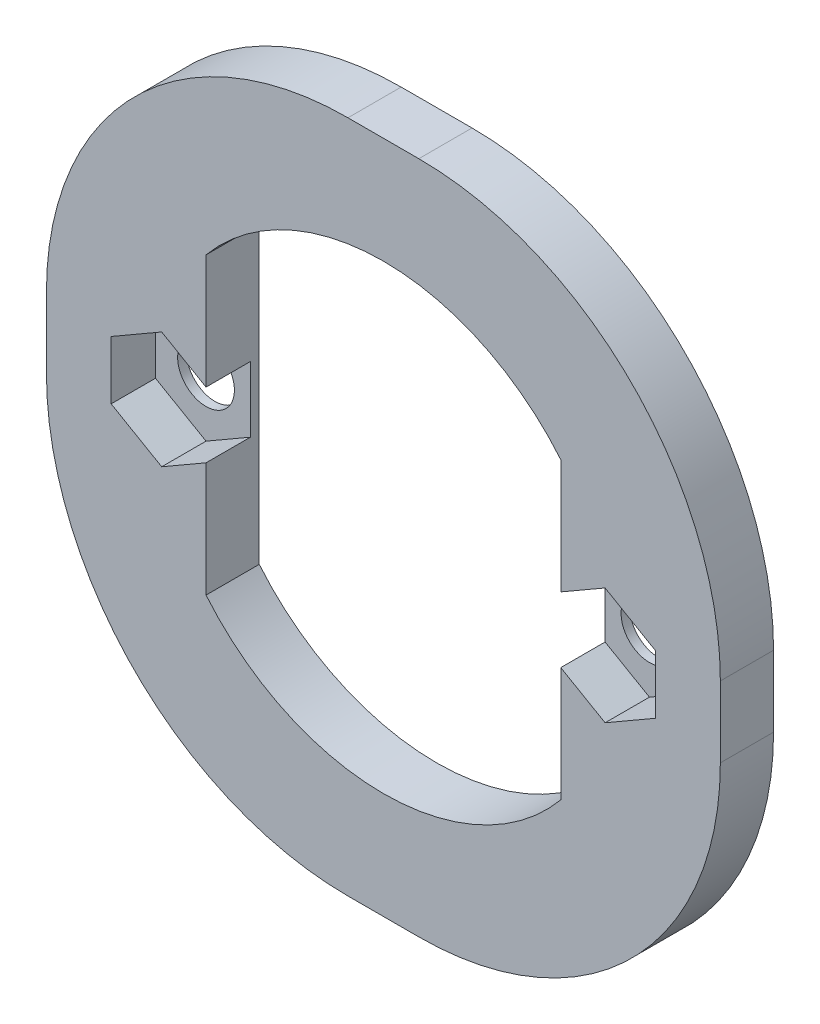
from build123d import *

# Parameters (mm, degrees)
BOSS_EXTRUDE5_DEPTH = 3
SKETCH2_R           = 1.6
CUT_EXTRUDE2_DEPTH  = 4
CUT_EXTRUDE3_DEPTH  = 2.5


with BuildPart() as part:
    # Sketch1 → Boss-Extrude5 (new body)
    with BuildSketch(Plane.XY):
        with BuildLine():
            Line((-1.997893001, -19), (1.997893001, -19))
            ThreePointArc((1.997893001, -19), (14.018708281, -14.02081528), (18.997893001, -2))
            Line((18.997893001, -2), (18.997893001, 2))
            ThreePointArc((18.997893001, 2), (14.018708281, 14.02081528), (1.997893001, 19))
            Line((1.997893001, 19), (-1.997893001, 19))
            ThreePointArc((-1.997893001, 19), (-14.018708281, 14.02081528), (-18.997893001, 2))
            Line((-18.997893001, 2), (-18.997893001, -2))
            ThreePointArc((-18.997893001, -2), (-14.018708281, -14.02081528), (-1.997893001, -19))
        make_face()
        with BuildLine():
            Line((-10, -8.306623863), (-10, 8.306623863))
            ThreePointArc((-10, 8.306623863), (0, 13), (10, 8.306623863))
            Line((10, 8.306623863), (10, -8.306623863))
            ThreePointArc((10, -8.306623863), (0, -13), (-10, -8.306623863))
        make_face(mode=Mode.SUBTRACT)
    extrude(amount=BOSS_EXTRUDE5_DEPTH)

    # Sketch2 → Cut-Extrude2 (cut, through all)
    with BuildSketch(Plane.XY.offset(3)):
        with Locations((-12.5, 0)):
            Circle(SKETCH2_R)
        with Locations((12.5, 0)):
            Circle(SKETCH2_R)
    extrude(amount=-CUT_EXTRUDE2_DEPTH, mode=Mode.SUBTRACT)

    # Sketch3 → Cut-Extrude3 (cut)
    with BuildSketch(Plane.XY.offset(3)):
        Polygon((-12.5, 3.290896534), (-15.35, 1.645448267), (-15.35, -1.645448267), (-12.5, -3.290896534), (-9.65, -1.645448267), (-9.65, 1.645448267), align=None)
        Polygon((12.5, 3.290896534), (9.65, 1.645448267), (9.65, -1.645448267), (12.5, -3.290896534), (15.35, -1.645448267), (15.35, 1.645448267), align=None)
    extrude(amount=-CUT_EXTRUDE3_DEPTH, mode=Mode.SUBTRACT)


solid = part.part
